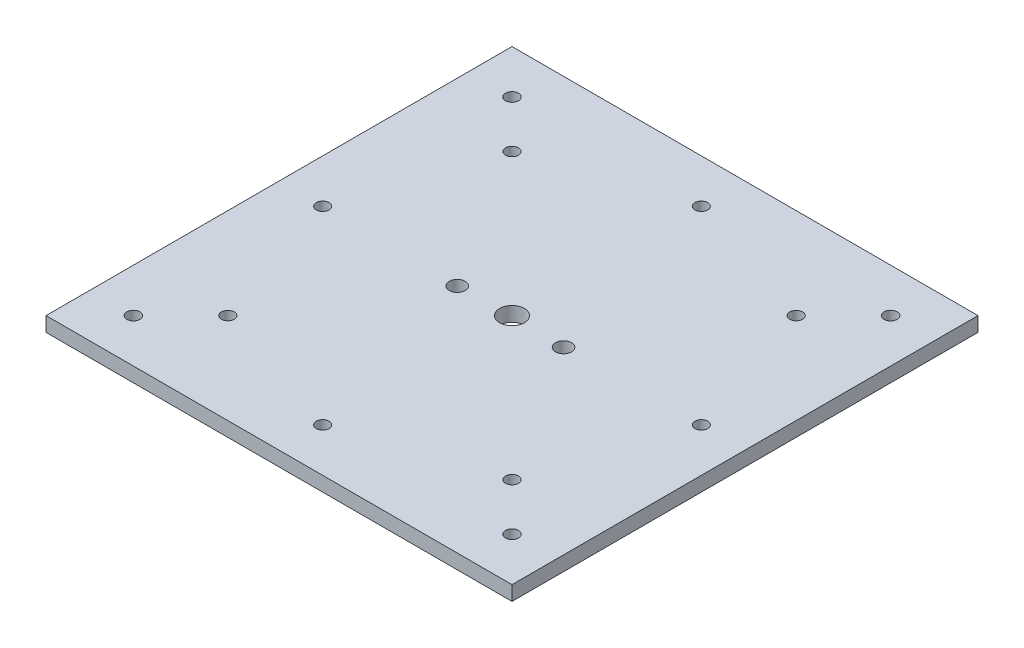
from build123d import *

# Parameters (mm, degrees)
SKETCH1_W           = 160
SKETCH1_H           = 160
SKETCH1_R           = 2.2
SKETCH1_R_2         = 4.25
SKETCH1_R_3         = 2.75
SKETCH1_R_4         = 2.25
BOSS_EXTRUDE1_DEPTH = 5


with BuildPart() as part:
    # Sketch1 → Boss-Extrude1 (new body)
    with BuildSketch(Plane(origin=(0, 0, 0), x_dir=(1, 0, 0), z_dir=(0, 1, 0))):
        Rectangle(SKETCH1_W, SKETCH1_H)
        with Locations((48.790367902, 48.790367902)):
            Circle(SKETCH1_R, mode=Mode.SUBTRACT)
        with Locations((48.790367902, -48.790367902)):
            Circle(SKETCH1_R, mode=Mode.SUBTRACT)
        with Locations((-48.790367902, -48.790367902)):
            Circle(SKETCH1_R, mode=Mode.SUBTRACT)
        with Locations((-48.790367902, 48.790367902)):
            Circle(SKETCH1_R, mode=Mode.SUBTRACT)
        Circle(SKETCH1_R_2, mode=Mode.SUBTRACT)
        with Locations((18.272421355, -0.571625498)):
            Circle(SKETCH1_R_3, mode=Mode.SUBTRACT)
        with Locations((-18.227578645, -0.571625498)):
            Circle(SKETCH1_R_3, mode=Mode.SUBTRACT)
        with Locations((0, 65)):
            Circle(SKETCH1_R, mode=Mode.SUBTRACT)
        with Locations((65, 0)):
            Circle(SKETCH1_R, mode=Mode.SUBTRACT)
        with Locations((0, -65)):
            Circle(SKETCH1_R, mode=Mode.SUBTRACT)
        with Locations((-65, 0)):
            Circle(SKETCH1_R, mode=Mode.SUBTRACT)
        with Locations((-65, 65)):
            Circle(SKETCH1_R_4, mode=Mode.SUBTRACT)
        with Locations((65, 65)):
            Circle(SKETCH1_R_4, mode=Mode.SUBTRACT)
        with Locations((65, -65)):
            Circle(SKETCH1_R_4, mode=Mode.SUBTRACT)
        with Locations((-65, -65)):
            Circle(SKETCH1_R_4, mode=Mode.SUBTRACT)
    extrude(amount=BOSS_EXTRUDE1_DEPTH)


solid = part.part
